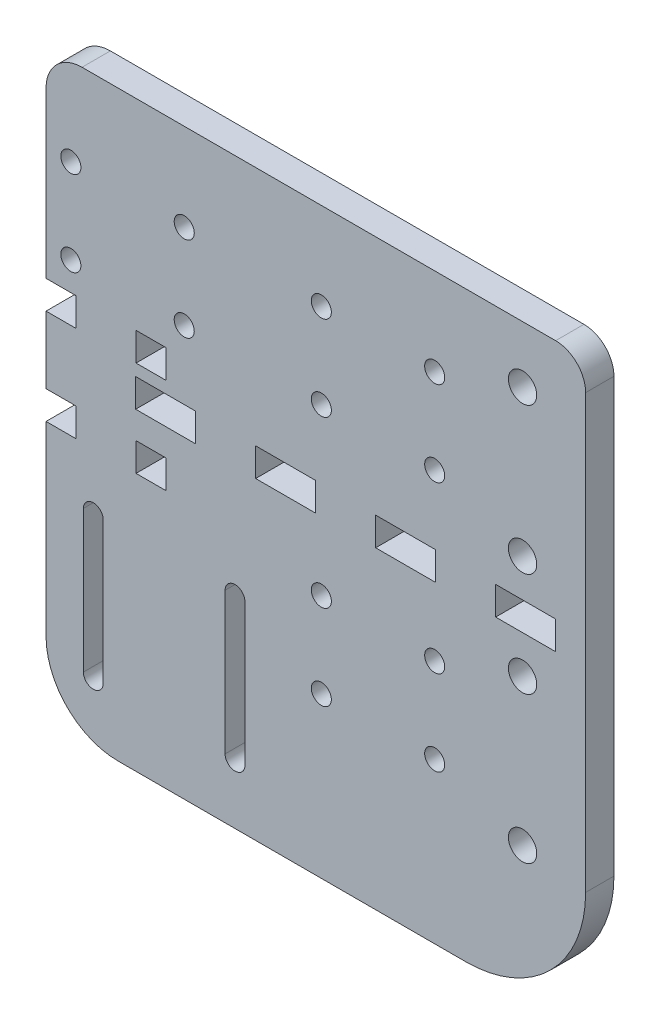
from build123d import *

# Parameters (mm, degrees)
SKETCH1_R           = 2.125
SKETCH1_R_2         = 3
SKETCH1_W           = 6.35
SKETCH1_H           = 6
SKETCH1_W_2         = 12.7
SKETCH1_H_2         = 5.9944
BOSS_EXTRUDE1_DEPTH = 5.9944


with BuildPart() as part:
    # Sketch1 → Boss-Extrude1 (new body)
    with BuildSketch(Plane(origin=(0, 0, 0), x_dir=(-1, 0, 0), z_dir=(0, 0, 1))):
        with BuildLine():
            Line((72.098749996, 7.383354962), (72.098749996, -6.840645038))
            Line((72.098749996, -6.840645038), (65.748749996, -6.840645038))
            Line((65.748749996, -6.840645038), (65.748749996, -12.840645038))
            Line((65.748749996, -12.840645038), (72.098749996, -12.840645038))
            Line((72.098749996, -12.840645038), (72.098749996, -42.840645038))
            Line((72.098749996, -42.840645038), (72.098749996, -47.734229729))
            ThreePointArc((72.098749996, -47.734229729), (69.866903669, -53.122383402), (64.478749996, -55.354229729))
            Line((64.478749996, -55.354229729), (51.652589936, -55.354229729))
            Line((51.652589936, -55.354229729), (45.302589935, -55.354229729))
            Line((45.302589935, -55.354229729), (26.252589932, -55.354229729))
            Line((26.252589932, -55.354229729), (-35.770420068, -55.354229729))
            ThreePointArc((-35.770420068, -55.354229729), (-40.260548128, -53.494357789), (-42.120420068, -49.004229729))
            Line((-42.120420068, -49.004229729), (-42.120420068, 42.61894002))
            ThreePointArc((-42.120420068, 42.61894002), (-34.68093231, 60.579452262), (-16.720420068, 68.01894002))
            Line((-16.720420068, 68.01894002), (56.858749996, 68.01894002))
            ThreePointArc((56.858749996, 68.01894002), (67.635057342, 63.555247365), (72.098749996, 52.77894002))
            Line((72.098749996, 52.77894002), (72.098749996, 13.383354962))
            Line((72.098749996, 13.383354962), (65.748749996, 13.383354962))
            Line((65.748749996, 13.383354962), (65.748749996, 7.383354962))
            Line((65.748749996, 7.383354962), (72.098749996, 7.383354962))
        make_face()
        with Locations((-10.170420063, -18.840645038)):
            Circle(SKETCH1_R, mode=Mode.SUBTRACT)
        with Locations((13.829579937, -18.840645038)):
            Circle(SKETCH1_R, mode=Mode.SUBTRACT)
        with Locations((13.829579937, -36.840645038)):
            Circle(SKETCH1_R, mode=Mode.SUBTRACT)
        with Locations((-10.170420063, -36.840645038)):
            Circle(SKETCH1_R, mode=Mode.SUBTRACT)
        with Locations((-28.770420063, -43.34064498)):
            Circle(SKETCH1_R_2, mode=Mode.SUBTRACT)
        with Locations((-28.770420063, -12.34064498)):
            Circle(SKETCH1_R_2, mode=Mode.SUBTRACT)
        with Locations((42.848749997, -18.840645038)):
            Circle(SKETCH1_R, mode=Mode.SUBTRACT)
        with Locations((66.848749997, -18.840645038)):
            Circle(SKETCH1_R, mode=Mode.SUBTRACT)
        with Locations((-28.770420063, 9.67852502)):
            Circle(SKETCH1_R_2, mode=Mode.SUBTRACT)
        with Locations((-28.770420063, 40.67852502)):
            Circle(SKETCH1_R_2, mode=Mode.SUBTRACT)
        with Locations((66.848749997, -36.840645038)):
            Circle(SKETCH1_R, mode=Mode.SUBTRACT)
        with Locations((42.848749997, -36.840645038)):
            Circle(SKETCH1_R, mode=Mode.SUBTRACT)
        with Locations((-10.170420063, 34.178525078)):
            Circle(SKETCH1_R, mode=Mode.SUBTRACT)
        with Locations((13.829579937, 34.178525078)):
            Circle(SKETCH1_R, mode=Mode.SUBTRACT)
        with Locations((-10.170420063, 16.178525078)):
            Circle(SKETCH1_R, mode=Mode.SUBTRACT)
        with Locations((13.829579937, 16.178525078)):
            Circle(SKETCH1_R, mode=Mode.SUBTRACT)
        with Locations((49.873749996, 10.383354962)):
            Rectangle(SKETCH1_W, SKETCH1_H, mode=Mode.SUBTRACT)
        with BuildLine():
            Line((34.198749996, 55.383354962), (34.198749996, 25.383354962))
            ThreePointArc((34.198749996, 25.383354962), (32.098749996, 23.283354962), (29.998749996, 25.383354962))
            Line((29.998749996, 25.383354962), (29.998749996, 55.383354962))
            ThreePointArc((29.998749996, 55.383354962), (32.098749996, 57.483354962), (34.198749996, 55.383354962))
        make_face(mode=Mode.SUBTRACT)
        with BuildLine():
            Line((64.198749996, 55.383354962), (64.198749996, 25.383354962))
            ThreePointArc((64.198749996, 25.383354962), (62.098749996, 23.283354962), (59.998749996, 25.383354962))
            Line((59.998749996, 25.383354962), (59.998749996, 55.383354962))
            ThreePointArc((59.998749996, 55.383354962), (62.098749996, 57.483354962), (64.198749996, 55.383354962))
        make_face(mode=Mode.SUBTRACT)
        with Locations((49.873749996, -9.840645038)):
            Rectangle(SKETCH1_W, SKETCH1_H, mode=Mode.SUBTRACT)
        with Locations((-29.420420063, -1.33105998)):
            Rectangle(SKETCH1_W_2, SKETCH1_H_2, mode=Mode.SUBTRACT)
        with Locations((-4.020420063, -1.33105998)):
            Rectangle(SKETCH1_W_2, SKETCH1_H_2, mode=Mode.SUBTRACT)
        with Locations((21.379579937, -1.33105998)):
            Rectangle(SKETCH1_W_2, SKETCH1_H_2, mode=Mode.SUBTRACT)
        with Locations((46.779579937, -1.33105998)):
            Rectangle(SKETCH1_W_2, SKETCH1_H_2, mode=Mode.SUBTRACT)
    extrude(amount=BOSS_EXTRUDE1_DEPTH)


solid = part.part
